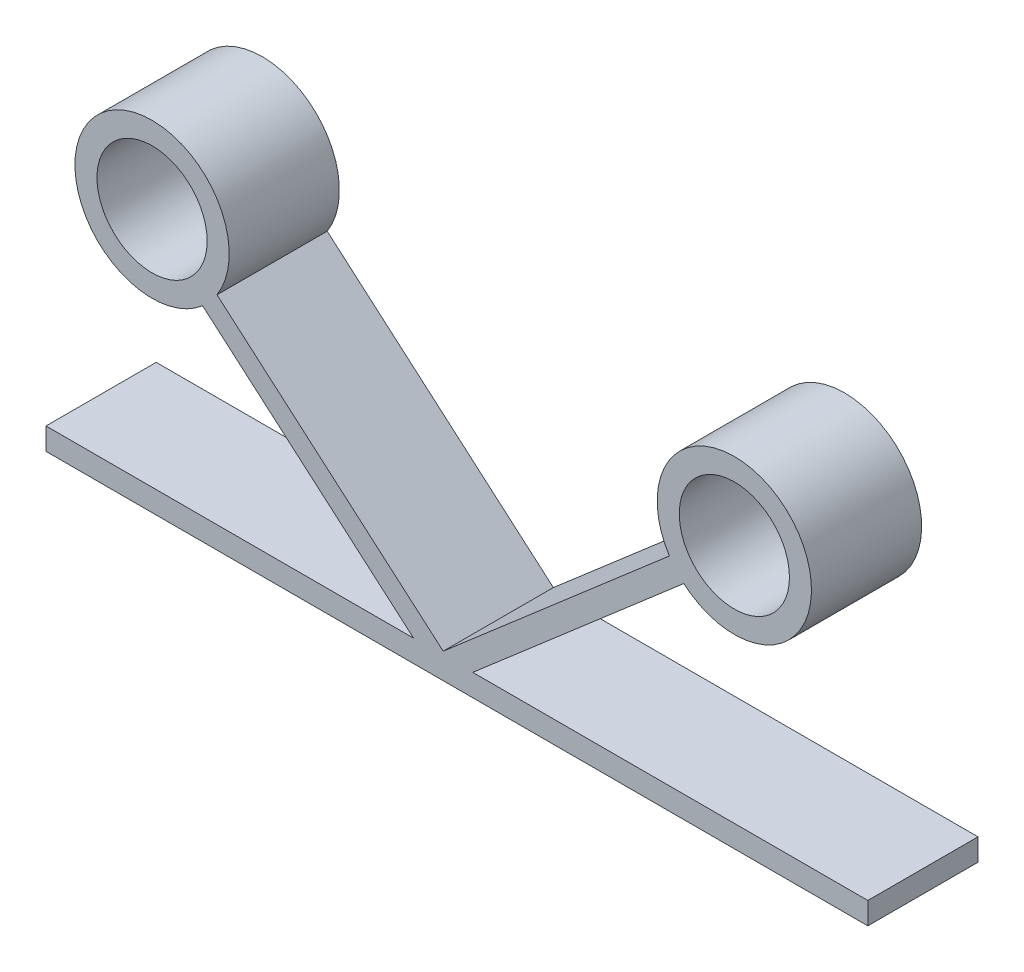
from build123d import *

# Parameters (mm, degrees)
SKETCH1_R               = 17.5
SKETCH1_R_2             = 12.5
EXTRUDE_THIN1_DEPTH     = 12.5
EXTRUDE_THIN1_2_DEPTH   = 12.5
SKETCH2_W               = 186.467509327
SKETCH2_H               = 5
EXTRUDE_THIN2_DEPTH     = 12.5
SKETCH3_W               = 9.044887752
SKETCH3_H               = 4.781773829
CUT_EXTRUDE1_DEPTH      = 13.5
CUT_EXTRUDE1_DEPTH_BACK = 13.5


with BuildPart() as part:
    # Sketch1 → Extrude-Thin1 (new body, symmetric)
    with BuildSketch(Plane.XY):
        with Locations((-66.06, 0)):
            Circle(SKETCH1_R)
        with Locations((-66.06, 0)):
            Circle(SKETCH1_R_2, mode=Mode.SUBTRACT)
    extrude(amount=EXTRUDE_THIN1_DEPTH, both=True)



with BuildPart() as body_2:
    # Sketch1 → Extrude-Thin1 2 (new body, symmetric)
    with BuildSketch(Plane.XY):
        with Locations((66.06, 0)):
            Circle(SKETCH1_R)
        with Locations((66.06, 0)):
            Circle(SKETCH1_R_2, mode=Mode.SUBTRACT)
    extrude(amount=EXTRUDE_THIN1_2_DEPTH, both=True)


with BuildPart() as part_1:
    add(part.part)

    add(body_2.part)  # Extrude-Thin2 merges body 2
    # Sketch2 → Extrude-Thin2 (add, symmetric)
    with BuildSketch(Plane.XY):
        Polygon((-57.1035212, -11.046786298), (0, -60.408556187), (56.960039317, -11.170815772), (53.690229399, -7.388178716), (0, -53.799410338), (-53.833711283, -7.264149241), align=None)
        with Locations((3.112302406, -57.103983263)):
            Rectangle(SKETCH2_W, SKETCH2_H)
    extrude(amount=EXTRUDE_THIN2_DEPTH, both=True)

    # Sketch3 → Cut-Extrude1 (cut, two sides)
    with BuildSketch(Plane.XY) as cut_extrude1_sk:
        with Locations((0.087674805, -61.994870178)):
            Rectangle(SKETCH3_W, SKETCH3_H)
    extrude(amount=CUT_EXTRUDE1_DEPTH, mode=Mode.SUBTRACT)
    extrude(cut_extrude1_sk.sketch, amount=-CUT_EXTRUDE1_DEPTH_BACK, mode=Mode.SUBTRACT)


solid = part_1.part
